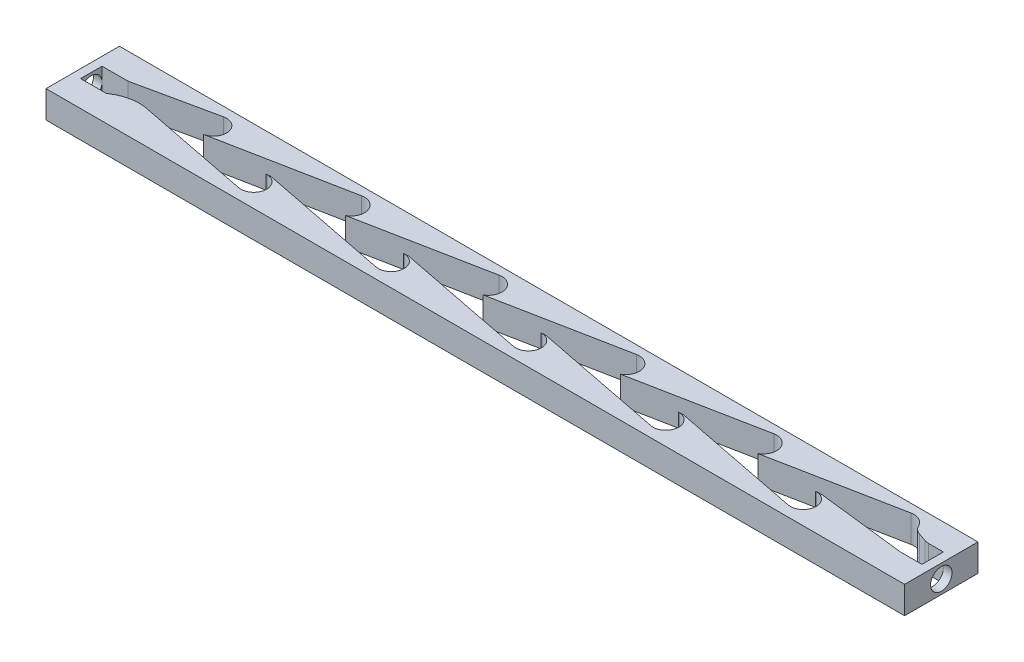
from build123d import *

# Parameters (mm, degrees)
SKETCH1_W           = 200
SKETCH1_H           = 17.1
BOSS_EXTRUDE1_DEPTH = 6.35
CUT_EXTRUDE1_REACH  = 8.35
CUT_EXTRUDE2_DEPTH  = 6.35
LPATTERN1_COUNT     = 5
LPATTERN1_PITCH     = 32
CUT_EXTRUDE3_DEPTH  = 6.35
LPATTERN2_COUNT     = 5
LPATTERN2_PITCH     = 32
FILLET1_R           = 10
CUT_EXTRUDE6_REACH  = 8.35
FILLET2_R           = 3
CUT_EXTRUDE7_REACH  = 202
SKETCH6_R           = 2.5
CUT_EXTRUDE8_REACH  = 202
SKETCH7_R           = 2.5


with BuildPart() as part:
    # Sketch1 → Boss-Extrude1 (new body)
    with BuildSketch(Plane(origin=(0, 0, 0), x_dir=(1, 0, 0), z_dir=(0, 1, 0))):
        with Locations((100, 8.55)):
            Rectangle(SKETCH1_W, SKETCH1_H)
    extrude(amount=BOSS_EXTRUDE1_DEPTH)

    # Sketch2 → Cut-Extrude1 (cut, up to next)
    with BuildSketch(Plane(origin=(0, 6.35, 0), x_dir=(1, 0, 0), z_dir=(0, 1, 0)), mode=Mode.PRIVATE) as cut_extrude1_sk1:
        with BuildLine():
            Line((2, 11.05), (8, 11.05))
            Line((8, 11.05), (26.371920214, 14.983515942))
            ThreePointArc((26.371920214, 14.983515942), (29.935888288, 12.666895422), (27.605702097, 9.111782008))
            Line((27.605702097, 9.111782008), (11.75, 8.5))
            Line((11.75, 8.5), (8, 6.05))
            Line((8, 6.05), (2, 6.05))
            Line((2, 6.05), (2, 11.05))
        make_face()
    cut_extrude1_tool1 = extrude(cut_extrude1_sk1.sketch, amount=-CUT_EXTRUDE1_REACH, mode=Mode.PRIVATE) & part.part
    add(cut_extrude1_tool1.solids().sort_by_distance((16.294125, 6.35, -10.477607))[0], mode=Mode.SUBTRACT)

    # Sketch3 → Cut-Extrude2 (cut)
    with BuildSketch(Plane(origin=(0, 6.35, 0), x_dir=(1, 0, 0), z_dir=(0, 1, 0))):
        with BuildLine():
            Line((42.420014497, 2.456597748), (11.75, 8.5))
            Line((11.75, 8.5), (27.605702097, 9.111782008))
            Line((27.605702097, 9.111782008), (43.1379451, 8.396826847))
            ThreePointArc((43.1379451, 8.396826847), (45.978326773, 5.040042176), (42.420014497, 2.456597748))
        make_face()
    cut_extrude2 = extrude(amount=-CUT_EXTRUDE2_DEPTH, mode=Mode.SUBTRACT)

    # LPattern1: Cut-Extrude2 ×5
    with Locations(*[(i * LPATTERN1_PITCH, 0, 0) for i in range(1, LPATTERN1_COUNT)]):
        add(cut_extrude2, mode=Mode.SUBTRACT)

    # Sketch4 → Cut-Extrude3 (cut)
    with BuildSketch(Plane(origin=(0, 6.35, 0), x_dir=(1, 0, 0), z_dir=(0, 1, 0))):
        with BuildLine():
            Line((27.605702097, 9.111782008), (58.394623882, 15.141281248))
            ThreePointArc((58.394623882, 15.141281248), (62.130306809, 12.401680657), (59.095650073, 8.901452547))
            Line((59.095650073, 8.901452547), (42.878228619, 8.408781697))
            Line((42.878228619, 8.408781697), (27.605702097, 9.111782008))
        make_face()
    cut_extrude3 = extrude(amount=-CUT_EXTRUDE3_DEPTH, mode=Mode.SUBTRACT)

    # LPattern2: Cut-Extrude3 ×5
    with Locations(*[(i * LPATTERN2_PITCH, 0, 0) for i in range(1, LPATTERN2_COUNT)]):
        add(cut_extrude3, mode=Mode.SUBTRACT)

    # Fillet1
    fillet1_edges = [part.edges().sort_by_distance(p)[0] for p in [
        (11.75, 3.175, -8.5),
    ]]
    fillet(fillet1_edges, radius=FILLET1_R)

    # Sketch5 → Cut-Extrude6 (cut, up to next)
    with BuildSketch(Plane(origin=(0, 6.35, 0), x_dir=(1, 0, 0), z_dir=(0, 1, 0)), mode=Mode.PRIVATE) as cut_extrude6_sk1:
        Polygon((198, 6.05), (193, 6.05), (172.348389916, 8.453443891), (190.130306809, 12.401680657), (194, 11.05), (198, 11.05), align=None)
    cut_extrude6_tool1 = extrude(cut_extrude6_sk1.sketch, amount=-CUT_EXTRUDE6_REACH, mode=Mode.PRIVATE) & part.part
    add(cut_extrude6_tool1.solids().sort_by_distance((188.45236, 6.35, -8.941649))[0], mode=Mode.SUBTRACT)

    # Fillet2
    fillet2_edges = [part.edges().sort_by_distance(p)[0] for p in [
        (190.130306809, 3.175, -12.401680657),
        (194, 3.175, -11.05),
    ]]
    fillet(fillet2_edges, radius=FILLET2_R)

    # Sketch6 → Cut-Extrude7 (cut, up to next)
    with BuildSketch(Plane(origin=(200, 0, 0), x_dir=(0, 0, -1), z_dir=(1, 0, 0)), mode=Mode.PRIVATE) as cut_extrude7_sk1:
        with Locations((8.55, 3.175)):
            Circle(SKETCH6_R)
    cut_extrude7_tool1 = extrude(cut_extrude7_sk1.sketch, amount=-CUT_EXTRUDE7_REACH, mode=Mode.PRIVATE) & part.part
    add(cut_extrude7_tool1.solids().sort_by_distance((200, 3.175, -8.55))[0], mode=Mode.SUBTRACT)

    # Sketch7 → Cut-Extrude8 (cut, up to next)
    with BuildSketch(Plane.ZY, mode=Mode.PRIVATE) as cut_extrude8_sk1:
        with Locations((-8.55, 3.175)):
            Circle(SKETCH7_R)
    cut_extrude8_tool1 = extrude(cut_extrude8_sk1.sketch, amount=-CUT_EXTRUDE8_REACH, mode=Mode.PRIVATE) & part.part
    add(cut_extrude8_tool1.solids().sort_by_distance((0, 3.175, -8.55))[0], mode=Mode.SUBTRACT)


solid = part.part
